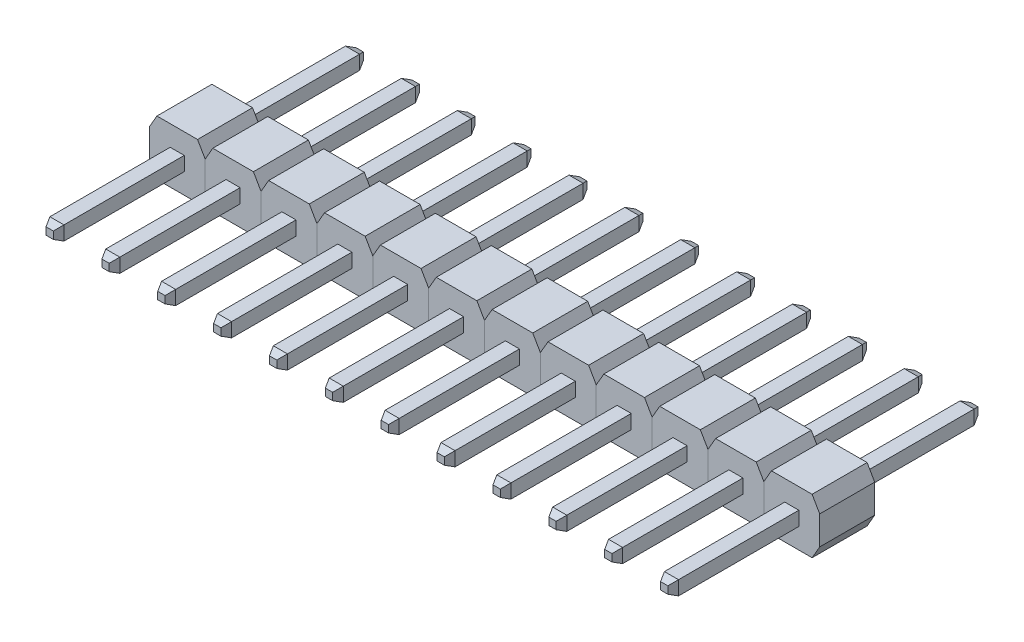
from build123d import *
from OCP.BRepFilletAPI import BRepFilletAPI_MakeChamfer

# Parameters (mm, degrees)
SKETCH_1_W             = 0.64
SKETCH_1_H             = 0.64
EXTRUDE_1_DEPTH        = 2.5
EXTRUDE_3_DEPTH        = 8.3
EXTRUDE_3_DEPTH_BACK   = 5.8
SKETCH_1_5_W           = 0.64
SKETCH_1_5_H           = 0.64
CHAMFER_1_SIZE         = 0.33
CHAMFER_1_SIZE2        = 0.153881527
CHAMFER_2_SIZE         = 0.33
CHAMFER_2_SIZE2        = 0.153881527
PATTERN_LINEAR_4_COUNT = 12
PATTERN_LINEAR_4_PITCH = 2.54


with BuildPart() as part:
    # Эскиз1 → Бобышка-Вытянуть1 (new body)
    with BuildSketch(Plane.XY):
        Polygon((1.243589838, -1.57), (-0.603589838, -1.57), (-0.95, -0.97), (-0.95, 0.33), (-0.603589838, 0.93), (1.243589838, 0.93), (1.59, 0.33), (1.59, -0.97), align=None)
        with Locations((0.32, -0.32)):
            Rectangle(SKETCH_1_W, SKETCH_1_H, mode=Mode.SUBTRACT)
    extrude(amount=EXTRUDE_1_DEPTH)

    # Эскиз1<5> → Бобышка-Вытянуть3 (add, two sides: drawn at the far end of the back side and taken through both)
    with BuildSketch(Plane.XY.offset(-EXTRUDE_3_DEPTH_BACK)):
        with Locations((0.32, -0.32)):
            Rectangle(SKETCH_1_5_W, SKETCH_1_5_H)
    extrude(amount=EXTRUDE_3_DEPTH + EXTRUDE_3_DEPTH_BACK)

    # Фаска1: one chamfer whose edges measure the first distance from different faces: ONE call of the kernel's chamfer builder (chamfer() names one face for all edges)
    chamfer_1_edges_1 = [part.edges().sort_by_distance(p)[0] for p in [
        (0, -0.32, -5.8),
    ]]
    chamfer_1_side_1 = [part.faces().sort_by_distance(p)[0] for p in [
        (0, -0.32, -2.9),
    ]]
    chamfer_1_edges_2 = [part.edges().sort_by_distance(p)[0] for p in [
        (0.32, -0.64, -5.8),
    ]]
    chamfer_1_side_2 = [part.faces().sort_by_distance(p)[0] for p in [
        (0.32, -0.64, -2.9),
    ]]
    chamfer_1_edges_3 = [part.edges().sort_by_distance(p)[0] for p in [
        (0.64, -0.32, -5.8),
    ]]
    chamfer_1_side_3 = [part.faces().sort_by_distance(p)[0] for p in [
        (0.64, -0.32, -2.9),
    ]]
    chamfer_1_edges_4 = [part.edges().sort_by_distance(p)[0] for p in [
        (0.32, 0, -5.8),
    ]]
    chamfer_1_side_4 = [part.faces().sort_by_distance(p)[0] for p in [
        (0.32, 0, -2.9),
    ]]
    chamfer_1 = BRepFilletAPI_MakeChamfer(part.part.solid().wrapped)
    for e in chamfer_1_edges_1:
        chamfer_1.Add(CHAMFER_1_SIZE, CHAMFER_1_SIZE2, e.wrapped, chamfer_1_side_1[0].wrapped)  # the first distance lies on this face
    for e in chamfer_1_edges_2:
        chamfer_1.Add(CHAMFER_1_SIZE, CHAMFER_1_SIZE2, e.wrapped, chamfer_1_side_2[0].wrapped)  # the first distance lies on this face
    for e in chamfer_1_edges_3:
        chamfer_1.Add(CHAMFER_1_SIZE, CHAMFER_1_SIZE2, e.wrapped, chamfer_1_side_3[0].wrapped)  # the first distance lies on this face
    for e in chamfer_1_edges_4:
        chamfer_1.Add(CHAMFER_1_SIZE, CHAMFER_1_SIZE2, e.wrapped, chamfer_1_side_4[0].wrapped)  # the first distance lies on this face
    add(Compound.cast(chamfer_1.Shape()), mode=Mode.REPLACE)

    # Фаска2: one chamfer whose edges measure the first distance from different faces: ONE call of the kernel's chamfer builder (chamfer() names one face for all edges)
    chamfer_2_edges_1 = [part.edges().sort_by_distance(p)[0] for p in [
        (0.64, -0.32, 8.3),
    ]]
    chamfer_2_side_1 = [part.faces().sort_by_distance(p)[0] for p in [
        (0.64, -0.32, 5.4),
    ]]
    chamfer_2_edges_2 = [part.edges().sort_by_distance(p)[0] for p in [
        (0.32, -0.64, 8.3),
    ]]
    chamfer_2_side_2 = [part.faces().sort_by_distance(p)[0] for p in [
        (0.32, -0.64, 5.4),
    ]]
    chamfer_2_edges_3 = [part.edges().sort_by_distance(p)[0] for p in [
        (0, -0.32, 8.3),
    ]]
    chamfer_2_side_3 = [part.faces().sort_by_distance(p)[0] for p in [
        (0, -0.32, 5.4),
    ]]
    chamfer_2_edges_4 = [part.edges().sort_by_distance(p)[0] for p in [
        (0.32, 0, 8.3),
    ]]
    chamfer_2_side_4 = [part.faces().sort_by_distance(p)[0] for p in [
        (0.32, 0, 5.4),
    ]]
    chamfer_2 = BRepFilletAPI_MakeChamfer(part.part.solid().wrapped)
    for e in chamfer_2_edges_1:
        chamfer_2.Add(CHAMFER_2_SIZE, CHAMFER_2_SIZE2, e.wrapped, chamfer_2_side_1[0].wrapped)  # the first distance lies on this face
    for e in chamfer_2_edges_2:
        chamfer_2.Add(CHAMFER_2_SIZE, CHAMFER_2_SIZE2, e.wrapped, chamfer_2_side_2[0].wrapped)  # the first distance lies on this face
    for e in chamfer_2_edges_3:
        chamfer_2.Add(CHAMFER_2_SIZE, CHAMFER_2_SIZE2, e.wrapped, chamfer_2_side_3[0].wrapped)  # the first distance lies on this face
    for e in chamfer_2_edges_4:
        chamfer_2.Add(CHAMFER_2_SIZE, CHAMFER_2_SIZE2, e.wrapped, chamfer_2_side_4[0].wrapped)  # the first distance lies on this face
    add(Compound.cast(chamfer_2.Shape()), mode=Mode.REPLACE)


with BuildPart() as pattern_linear_4_1:
    # Линейный массив4: pattern copy
    add(part.part.moved(Location(Vector(-1, 0, 0) * (1 * PATTERN_LINEAR_4_PITCH))))


with BuildPart() as pattern_linear_4_2:
    # Линейный массив4: pattern copy
    add(part.part.moved(Location(Vector(-1, 0, 0) * (2 * PATTERN_LINEAR_4_PITCH))))


with BuildPart() as pattern_linear_4_3:
    # Линейный массив4: pattern copy
    add(part.part.moved(Location(Vector(-1, 0, 0) * (3 * PATTERN_LINEAR_4_PITCH))))


with BuildPart() as pattern_linear_4_4:
    # Линейный массив4: pattern copy
    add(part.part.moved(Location(Vector(-1, 0, 0) * (4 * PATTERN_LINEAR_4_PITCH))))


with BuildPart() as pattern_linear_4_5:
    # Линейный массив4: pattern copy
    add(part.part.moved(Location(Vector(-1, 0, 0) * (5 * PATTERN_LINEAR_4_PITCH))))


with BuildPart() as pattern_linear_4_6:
    # Линейный массив4: pattern copy
    add(part.part.moved(Location(Vector(-1, 0, 0) * (6 * PATTERN_LINEAR_4_PITCH))))


with BuildPart() as pattern_linear_4_7:
    # Линейный массив4: pattern copy
    add(part.part.moved(Location(Vector(-1, 0, 0) * (7 * PATTERN_LINEAR_4_PITCH))))


with BuildPart() as pattern_linear_4_8:
    # Линейный массив4: pattern copy
    add(part.part.moved(Location(Vector(-1, 0, 0) * (8 * PATTERN_LINEAR_4_PITCH))))


with BuildPart() as pattern_linear_4_9:
    # Линейный массив4: pattern copy
    add(part.part.moved(Location(Vector(-1, 0, 0) * (9 * PATTERN_LINEAR_4_PITCH))))


with BuildPart() as pattern_linear_4_10:
    # Линейный массив4: pattern copy
    add(part.part.moved(Location(Vector(-1, 0, 0) * (10 * PATTERN_LINEAR_4_PITCH))))


with BuildPart() as pattern_linear_4_11:
    # Линейный массив4: pattern copy
    add(part.part.moved(Location(Vector(-1, 0, 0) * (11 * PATTERN_LINEAR_4_PITCH))))


solid = Compound([part.part, pattern_linear_4_1.part, pattern_linear_4_2.part, pattern_linear_4_3.part, pattern_linear_4_4.part, pattern_linear_4_5.part, pattern_linear_4_6.part, pattern_linear_4_7.part, pattern_linear_4_8.part, pattern_linear_4_9.part, pattern_linear_4_10.part, pattern_linear_4_11.part])
